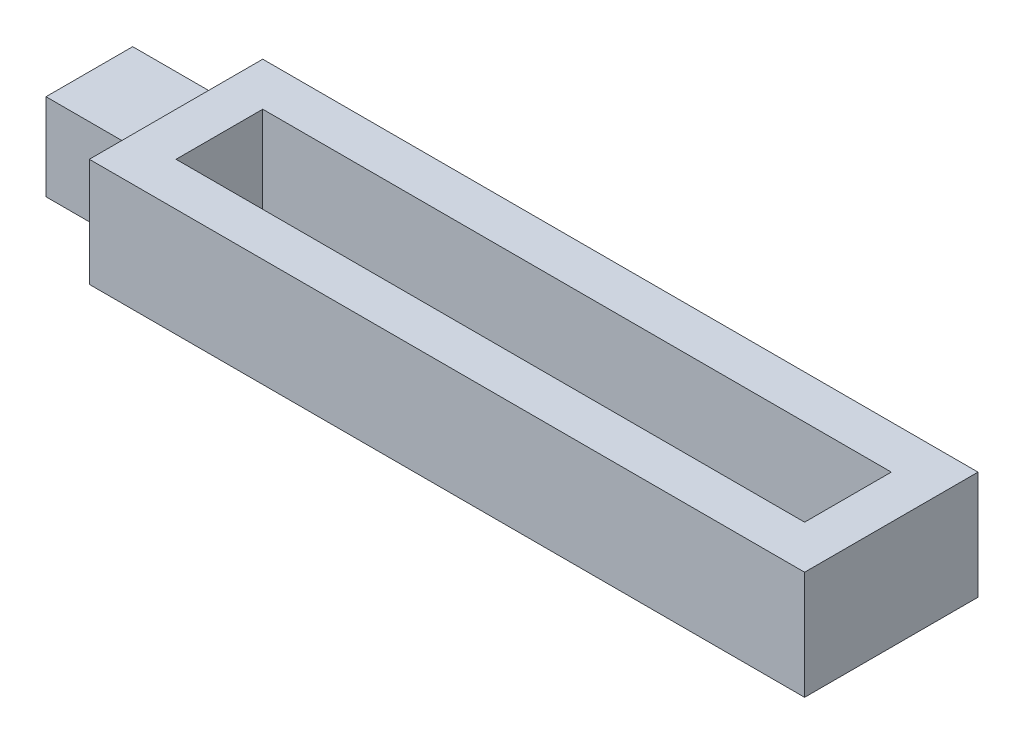
from build123d import *

# Parameters (mm, degrees)
BOSS_EXTRUDE1_DEPTH      = 50
BOSS_EXTRUDE1_DEPTH_BACK = 50
SKETCH1_W                = 580
SKETCH1_H                = 80
BOSS_EXTRUDE2_DEPTH      = 40
BOSS_EXTRUDE2_DEPTH_BACK = 40
SKETCH1_3_W              = 80
SKETCH1_3_H              = 80


with BuildPart() as part:
    # Sketch1 → Boss-Extrude1 (new, two sides: drawn at the far end of the back side and taken through both)
    with BuildSketch(Plane(origin=(0, 0, 0), x_dir=(1, 0, 0), z_dir=(0, 1, 0)).offset(-BOSS_EXTRUDE1_DEPTH_BACK)):
        Polygon((330, 80), (-330, 80), (-330, 40), (-330, -40), (-330, -80), (330, -80), align=None)
        Rectangle(SKETCH1_W, SKETCH1_H, mode=Mode.SUBTRACT)
    extrude(amount=BOSS_EXTRUDE1_DEPTH + BOSS_EXTRUDE1_DEPTH_BACK)

    # Sketch1_3 → Boss-Extrude2 (add, two sides: drawn at the far end of the back side and taken through both)
    with BuildSketch(Plane(origin=(0, 0, 0), x_dir=(1, 0, 0), z_dir=(0, 1, 0)).offset(-BOSS_EXTRUDE2_DEPTH_BACK)):
        with Locations((-370, 0)):
            Rectangle(SKETCH1_3_W, SKETCH1_3_H)
    extrude(amount=BOSS_EXTRUDE2_DEPTH + BOSS_EXTRUDE2_DEPTH_BACK)


solid = part.part
